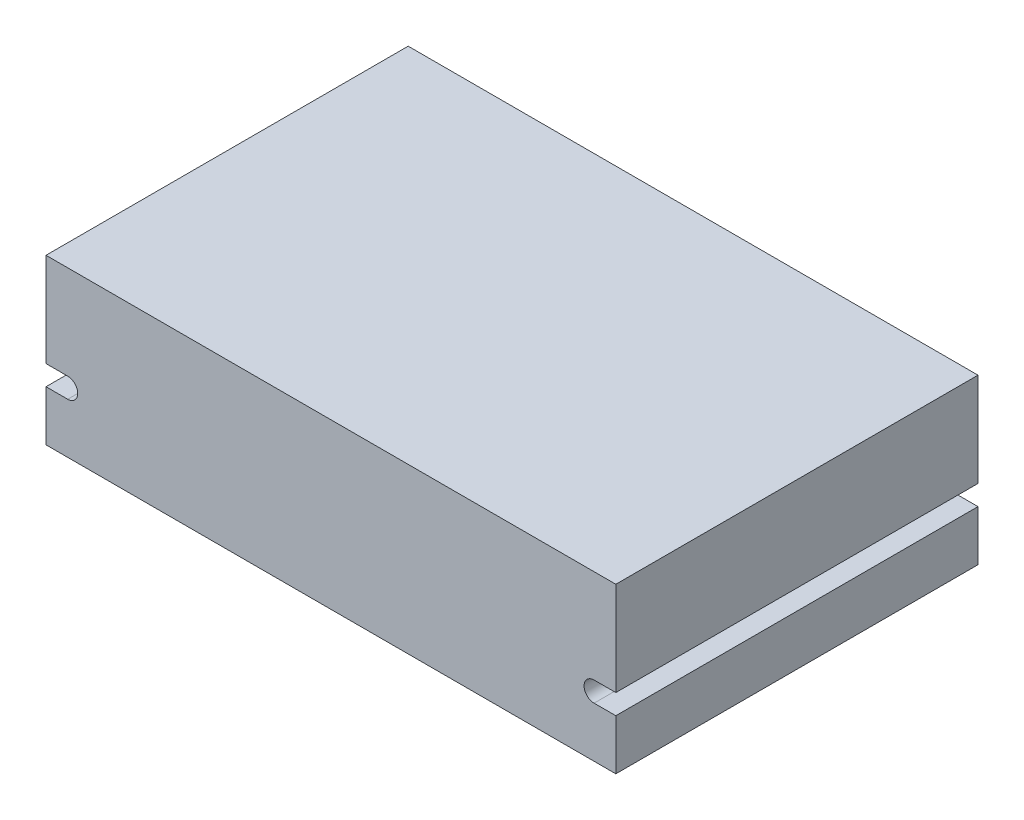
from build123d import *

# Parameters (mm, degrees)
ESTRUSIONE_ESTRUSIONE1_DEPTH = 75


with BuildPart() as part:
    # Schizzo1 → Estrusione-Estrusione1 (new body)
    with BuildSketch(Plane.XY):
        with BuildLine():
            Line((-56.75, 17), (61.25, 17))
            Line((61.25, 17), (61.25, -2.426773282))
            Line((61.25, -2.426773282), (56.75, -2.426773282))
            ThreePointArc((56.75, -2.426773282), (54.676773282, -4.5), (56.75, -6.573226718))
            Line((56.75, -6.573226718), (61.25, -6.573226718))
            Line((61.25, -6.573226718), (61.25, -17))
            Line((61.25, -17), (-56.75, -17))
            Line((-56.75, -17), (-56.75, -6.573226718))
            Line((-56.75, -6.573226718), (-52.25, -6.573226718))
            ThreePointArc((-52.25, -6.573226718), (-50.176773282, -4.5), (-52.25, -2.426773282))
            Line((-52.25, -2.426773282), (-56.75, -2.426773282))
            Line((-56.75, -2.426773282), (-56.75, 17))
        make_face()
    extrude(amount=ESTRUSIONE_ESTRUSIONE1_DEPTH)


solid = part.part
